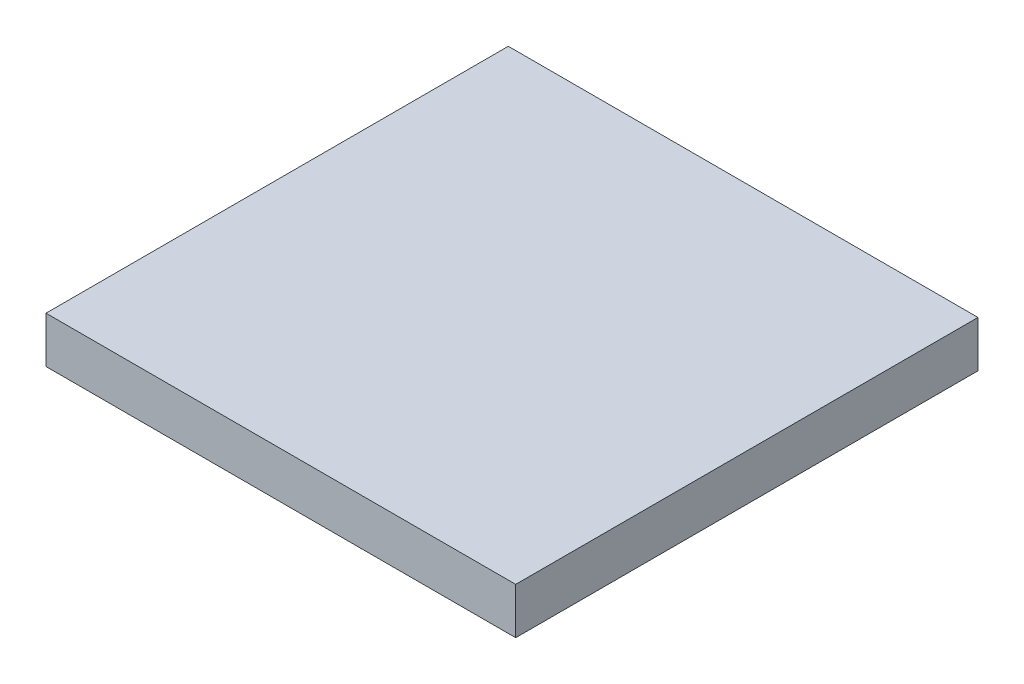
from build123d import *

# Parameters (mm, degrees)
SKETCH1_W           = 50.8
SKETCH1_H           = 50
BOSS_EXTRUDE1_DEPTH = 5


with BuildPart() as part:
    # Sketch1 → Boss-Extrude1 (new body)
    with BuildSketch(Plane(origin=(0, 0, 0), x_dir=(1, 0, 0), z_dir=(0, 1, 0))):
        Rectangle(SKETCH1_W, SKETCH1_H)
    extrude(amount=BOSS_EXTRUDE1_DEPTH)


solid = part.part
